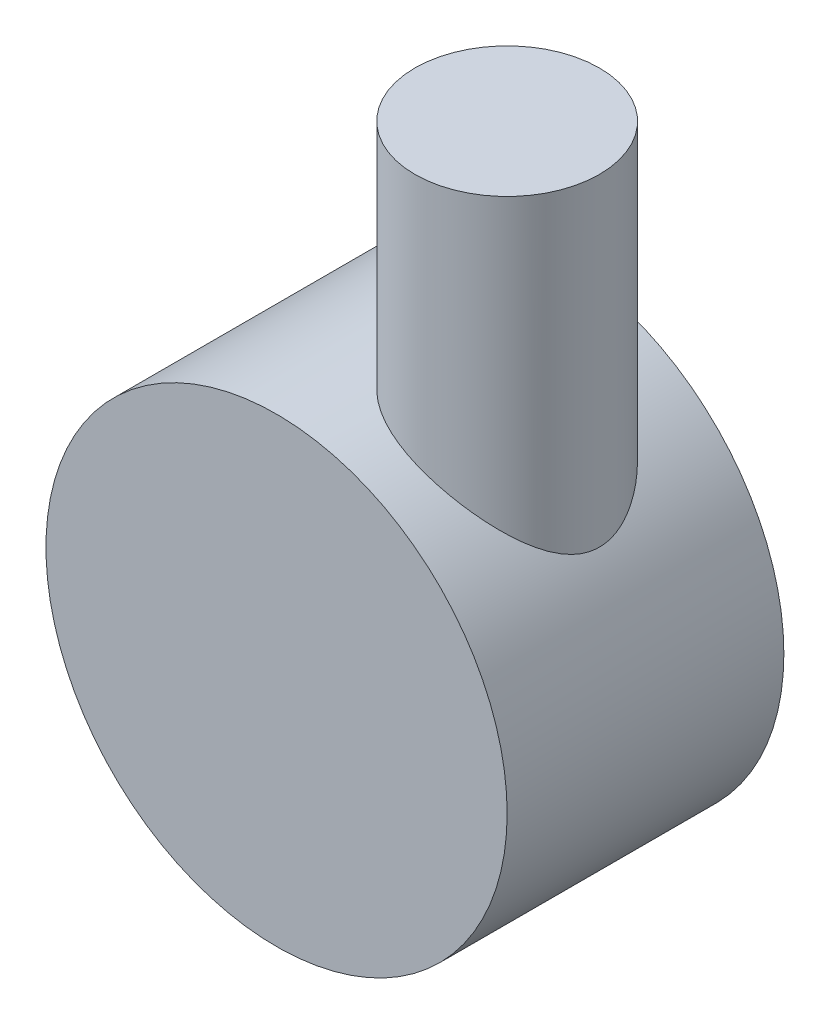
from build123d import *

# Parameters (mm, degrees)
SKETCH1_R           = 25
BOSS_EXTRUDE1_DEPTH = 30
SKETCH2_R           = 10
BOSS_EXTRUDE2_DEPTH = 50


with BuildPart() as part:
    # Sketch1 → Boss-Extrude1 (new body)
    with BuildSketch(Plane.XY):
        Circle(SKETCH1_R)
    extrude(amount=BOSS_EXTRUDE1_DEPTH)

    # Sketch2 → Boss-Extrude2 (add)
    with BuildSketch(Plane(origin=(0, 0, 0), x_dir=(1, 0, 0), z_dir=(0, 1, 0))):
        with Locations((10, -15)):
            Circle(SKETCH2_R)
    extrude(amount=BOSS_EXTRUDE2_DEPTH)


solid = part.part
